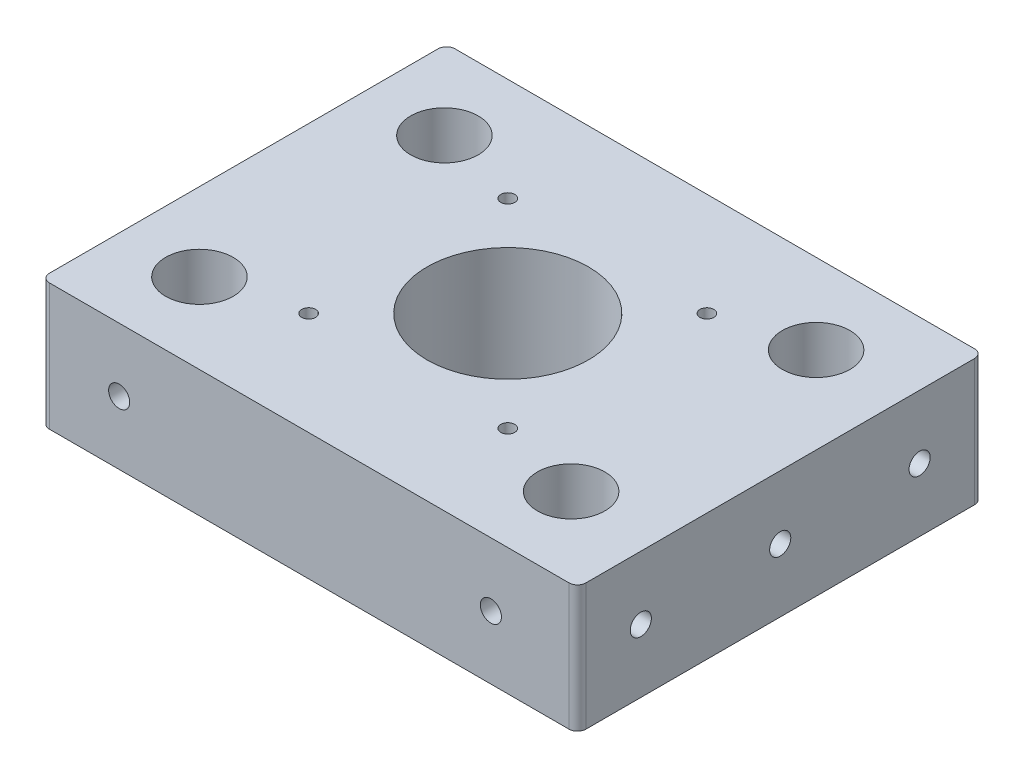
from build123d import *

# Parameters (mm, degrees)
SKETCH2_W                  = 125
SKETCH2_H                  = 96
SKETCH2_R                  = 8
SKETCH2_R_2                = 19.1
BOSS_EXTRUDE1_DEPTH        = 30
M4X0_7_TAPPED_HOLE1_D      = 3.3
SKETCH10_W                 = 96
SKETCH10_H                 = 30
BOSS_EXTRUDE3_DEPTH        = 2
M6X1_0_TAPPED_HOLE1_D      = 5
M6X1_0_TAPPED_HOLE1_DEPTH  = 11
M6X1_0_TAPPED_HOLE1_TIP    = 1.502151548
M6X1_0_TAPPED_HOLE3_REACH  = 121.483
M6X1_0_TAPPED_HOLE3_BORE_R = 2.5
FILLET1_R                  = 2


with BuildPart() as part:
    # Sketch2 → Boss-Extrude1 (new body)
    with BuildSketch(Plane(origin=(0, 0, 0), x_dir=(1, 0, 0), z_dir=(0, 1, 0))):
        Rectangle(SKETCH2_W, SKETCH2_H)
        with Locations(Location((-44, 29, 0), (0, 0, 270))):
            Circle(SKETCH2_R, mode=Mode.SUBTRACT)
        with Locations(Location((-44, -29, 0), (0, 0, 270))):
            Circle(SKETCH2_R, mode=Mode.SUBTRACT)
        with Locations(Location((44, -29, 0), (0, 0, 270))):
            Circle(SKETCH2_R, mode=Mode.SUBTRACT)
        with Locations(Location((44, 29, 0), (0, 0, 270))):
            Circle(SKETCH2_R, mode=Mode.SUBTRACT)
        with Locations(Location((0, 0, 0), (0, 0, 270))):
            Circle(SKETCH2_R_2, mode=Mode.SUBTRACT)
    extrude(amount=BOSS_EXTRUDE1_DEPTH)

    # M4x0.7 Tapped Hole1 (through all)
    with Locations(Plane(origin=(0, 30, 0), x_dir=(1, 0, 0), z_dir=(0, 1, 0))):
        with Locations((-23.5712, 23.5712), (23.5712, 23.5712), (23.5712, -23.5712), (-23.5712, -23.5712)):
            Hole(M4X0_7_TAPPED_HOLE1_D / 2)

    # Sketch10 → Boss-Extrude3 (add)
    with BuildSketch(Plane(origin=(62.5, 0, 0), x_dir=(0, 0, -1), z_dir=(1, 0, 0))):
        with Locations((0, 15)):
            Rectangle(SKETCH10_W, SKETCH10_H)
    extrude(amount=BOSS_EXTRUDE3_DEPTH)

    # M6x1.0 Tapped Hole1
    with Locations(Plane(origin=(64.5, 0, 0), x_dir=(0, 0, -1), z_dir=(1, 0, 0))):
        with Locations((-33, 15), (0, 15), (33, 15)):
            Hole(M6X1_0_TAPPED_HOLE1_D / 2, depth=M6X1_0_TAPPED_HOLE1_DEPTH)
            with Locations((0, 0, -(M6X1_0_TAPPED_HOLE1_DEPTH + M6X1_0_TAPPED_HOLE1_TIP / 2))):  # 118° drill point
                Cone(0, M6X1_0_TAPPED_HOLE1_D / 2, M6X1_0_TAPPED_HOLE1_TIP, mode=Mode.SUBTRACT)

    # M6x1.0 Tapped Hole3 bore → M6x1.0 Tapped Hole3 (cut, up to next)
    with BuildSketch(Plane(origin=(0, 0, -48), x_dir=(-1, 0, 0), z_dir=(0, 0, -1)), mode=Mode.PRIVATE) as m6x1_0_tapped_hole3_sk1:
        with Locations((-44, 15)):
            Circle(M6X1_0_TAPPED_HOLE3_BORE_R)
    m6x1_0_tapped_hole3_tool1 = extrude(m6x1_0_tapped_hole3_sk1.sketch, amount=-M6X1_0_TAPPED_HOLE3_REACH, mode=Mode.PRIVATE) & part.part
    # M6x1.0 Tapped Hole3 bore → M6x1.0 Tapped Hole3 (cut, up to next)
    with BuildSketch(Plane(origin=(0, 0, -48), x_dir=(-1, 0, 0), z_dir=(0, 0, -1)), mode=Mode.PRIVATE) as m6x1_0_tapped_hole3_sk2:
        with Locations((44, 15)):
            Circle(M6X1_0_TAPPED_HOLE3_BORE_R)
    m6x1_0_tapped_hole3_tool2 = extrude(m6x1_0_tapped_hole3_sk2.sketch, amount=-M6X1_0_TAPPED_HOLE3_REACH, mode=Mode.PRIVATE) & part.part
    m6x1_0_tapped_hole3_1 = m6x1_0_tapped_hole3_tool1.solids().sort_by_distance((44, 15, -48))[0]
    add(m6x1_0_tapped_hole3_1, mode=Mode.SUBTRACT)
    m6x1_0_tapped_hole3_2 = m6x1_0_tapped_hole3_tool2.solids().sort_by_distance((-44, 15, -48))[0]
    add(m6x1_0_tapped_hole3_2, mode=Mode.SUBTRACT)
    m6x1_0_tapped_hole3 = m6x1_0_tapped_hole3_1 + m6x1_0_tapped_hole3_2  # M6x1.0 Tapped Hole3 as one shape, for the pattern or mirror that repeats it

    # Fillet1
    fillet1_edges = [part.edges().sort_by_distance(p)[0] for p in [
        (64.5, 15, 48),
        (64.5, 15, -48),
        (-62.5, 15, -48),
        (-62.5, 15, 48),
    ]]
    fillet(fillet1_edges, radius=FILLET1_R)

    # Mirror1: M6x1.0 Tapped Hole3 across plane
    add(m6x1_0_tapped_hole3.mirror(Plane.XY), mode=Mode.SUBTRACT)


solid = part.part
